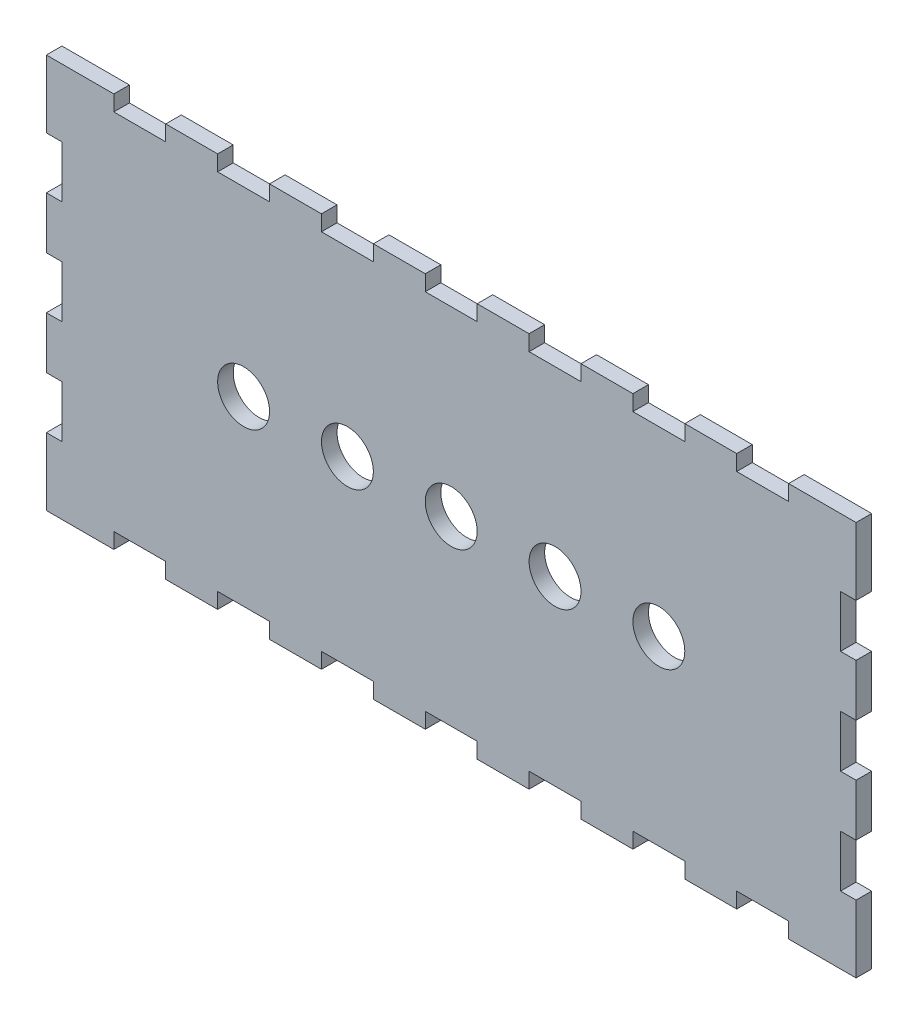
from build123d import *

# Parameters (mm, degrees)
SKETCH1_R           = 5
BOSS_EXTRUDE1_DEPTH = 3


with BuildPart() as part:
    # Sketch1 → Boss-Extrude1 (new body)
    with BuildSketch(Plane.XY):
        Polygon((0, 60), (0, 50), (-3, 50), (-3, 40), (0, 40), (0, 30), (-3, 30), (-3, 20), (0, 20), (0, 10), (-3, 10), (-3, 0), (-3, -3), (0, -3), (10, -3), (10, 0), (20, 0), (20, -3), (30, -3), (30, 0), (40, 0), (40, -3), (50, -3), (50, 0), (60, 0), (60, -3), (70, -3), (70, 0), (80, 0), (80, -3), (90, -3), (90, 0), (100, 0), (100, -3), (110, -3), (110, 0), (120, 0), (120, -3), (130, -3), (130, 0), (140, 0), (140, -3), (150, -3), (153, -3), (153, 0), (153, 10), (150, 10), (150, 20), (153, 20), (153, 30), (150, 30), (150, 40), (153, 40), (153, 50), (150, 50), (150, 60), (153, 60), (153, 70), (153, 73), (150, 73), (140, 73), (140, 70), (130, 70), (130, 73), (120, 73), (120, 70), (110, 70), (110, 73), (100, 73), (100, 70), (90, 70), (90, 73), (80, 73), (80, 70), (70, 70), (70, 73), (60, 73), (60, 70), (50, 70), (50, 73), (40, 73), (40, 70), (30, 70), (30, 73), (20, 73), (20, 70), (10, 70), (10, 73), (0, 73), (-3, 73), (-3, 70), (-3, 60), align=None)
        with Locations((35, 35)):
            Circle(SKETCH1_R, mode=Mode.SUBTRACT)
        with Locations((55, 35)):
            Circle(SKETCH1_R, mode=Mode.SUBTRACT)
        with Locations((75, 35)):
            Circle(SKETCH1_R, mode=Mode.SUBTRACT)
        with Locations((95, 35)):
            Circle(SKETCH1_R, mode=Mode.SUBTRACT)
        with Locations((115, 35)):
            Circle(SKETCH1_R, mode=Mode.SUBTRACT)
    extrude(amount=BOSS_EXTRUDE1_DEPTH)


solid = part.part
